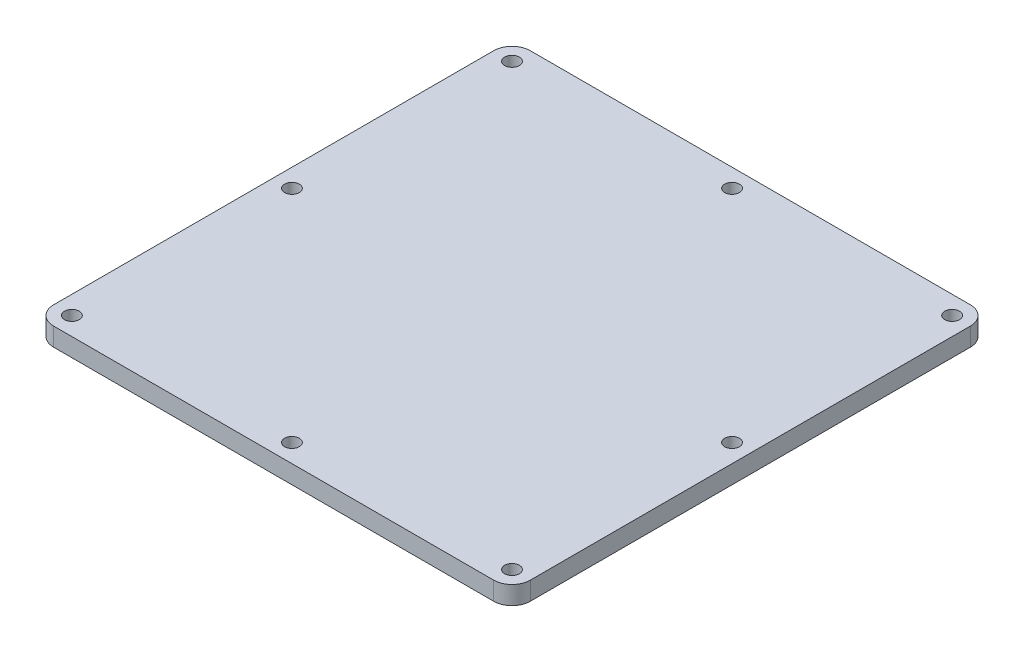
from build123d import *

# Parameters (mm, degrees)
SKETCH1_W              = 165.1
SKETCH1_H              = 165.1
BOSS_EXTRUDE1_DEPTH    = 6.35
FILLET1_R              = 6.35
F_10_CLEARANCE_HOLE1_D = 5.1054


with BuildPart() as part:
    # Sketch1 → Boss-Extrude1 (new body)
    with BuildSketch(Plane(origin=(0, 0, 0), x_dir=(1, 0, 0), z_dir=(0, 1, 0))):
        Rectangle(SKETCH1_W, SKETCH1_H)
    extrude(amount=BOSS_EXTRUDE1_DEPTH)

    # Fillet1
    fillet1_edges = [part.edges().sort_by_distance(p)[0] for p in [
        (-82.55, 3.175, -82.55),
        (82.55, 3.175, -82.55),
        (82.55, 3.175, 82.55),
        (-82.55, 3.175, 82.55),
    ]]
    fillet(fillet1_edges, radius=FILLET1_R)

    # #10 Clearance Hole1 (through all)
    with Locations(Plane(origin=(0, 6.35, 0), x_dir=(1, 0, 0), z_dir=(0, 1, 0))):
        with Locations((-76.2, -76.2), (-76.2, 76.2), (76.2, 76.2), (76.2, -76.2), (0, 76.2), (0, -76.2), (-76.2, 0), (76.2, 0)):
            Hole(F_10_CLEARANCE_HOLE1_D / 2)


solid = part.part
